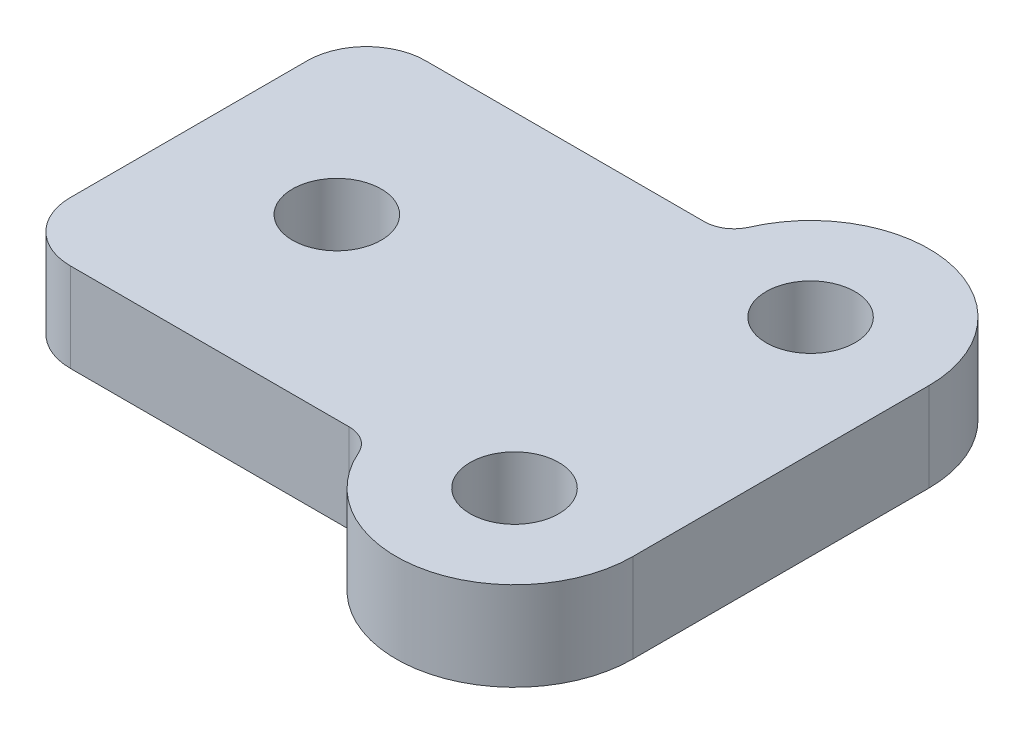
from build123d import *

# Parameters (mm, degrees)
SKETCH1_R           = 1.5
BOSS_EXTRUDE1_DEPTH = 3


with BuildPart() as part:
    # Sketch1 → Boss-Extrude1 (new body)
    with BuildSketch(Plane(origin=(0, 0, 0), x_dir=(1, 0, 0), z_dir=(0, 1, 0))):
        with BuildLine():
            Line((15, 5), (15, -5))
            ThreePointArc((15, -5), (11.817238575, -8.915625252), (7.333939444, -6.6))
            ThreePointArc((7.333939444, -6.6), (6.965146863, -6.163339973), (6.417424305, -6))
            Line((6.417424305, -6), (-3, -6))
            ThreePointArc((-3, -6), (-4.414213562, -5.414213562), (-5, -4))
            Line((-5, -4), (-5, 4))
            ThreePointArc((-5, 4), (-4.414213562, 5.414213562), (-3, 6))
            Line((-3, 6), (6.417424305, 6))
            ThreePointArc((6.417424305, 6), (6.965146863, 6.163339973), (7.333939444, 6.6))
            ThreePointArc((7.333939444, 6.6), (11.817238575, 8.915625252), (15, 5))
        make_face()
        Circle(SKETCH1_R, mode=Mode.SUBTRACT)
        with Locations((11, 5)):
            Circle(SKETCH1_R, mode=Mode.SUBTRACT)
        with Locations((11, -5)):
            Circle(SKETCH1_R, mode=Mode.SUBTRACT)
    extrude(amount=BOSS_EXTRUDE1_DEPTH)


solid = part.part
